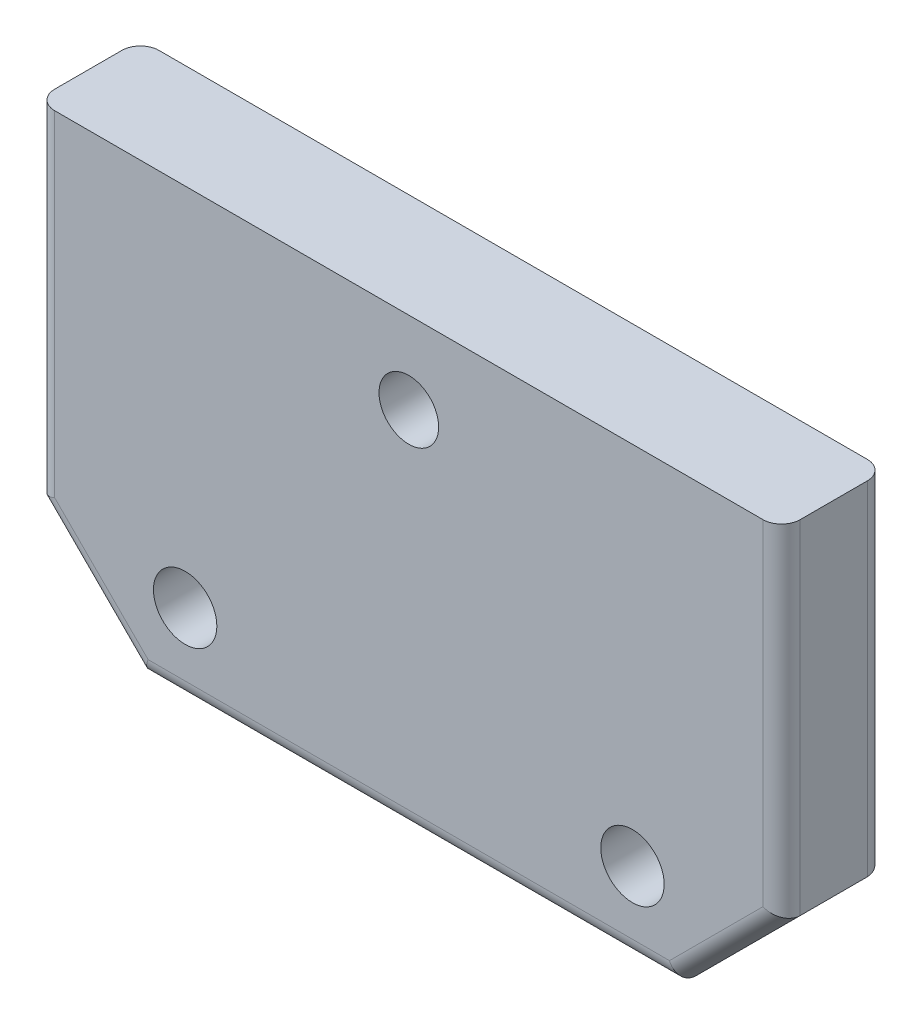
from build123d import *

# Parameters (mm, degrees)
SKETCH1_W           = 100
SKETCH1_H           = 60
SKETCH1_R           = 4.25
SKETCH1_R_2         = 4
BOSS_EXTRUDE1_DEPTH = 7
SKETCH2_R           = 6.457332118
BOSS_EXTRUDE2_DEPTH = 6
CHAMFER1_SIZE       = 14
FILLET2_R           = 2.5
SKETCH3_W           = 30
SKETCH3_H           = 22
CUT_EXTRUDE1_DEPTH  = 6
SKETCH4_R           = 1.25
CUT_EXTRUDE2_DEPTH  = 12


with BuildPart() as part:
    # Sketch1 → Boss-Extrude1 (new body, symmetric)
    with BuildSketch(Plane.XY):
        with Locations((0, 20)):
            Rectangle(SKETCH1_W, SKETCH1_H)
        with Locations((30, 1)):
            Circle(SKETCH1_R, mode=Mode.SUBTRACT)
        with Locations((-30, 1)):
            Circle(SKETCH1_R, mode=Mode.SUBTRACT)
        with Locations((0, 39)):
            Circle(SKETCH1_R_2, mode=Mode.SUBTRACT)
    extrude(amount=BOSS_EXTRUDE1_DEPTH, both=True)

    # Sketch2 → Boss-Extrude2 (add)
    with BuildSketch(Plane(origin=(0, 0, -7), x_dir=(-1, 0, 0), z_dir=(0, 0, -1))):
        with Locations((-30, 1)):
            Circle(SKETCH2_R)
        with Locations((30, 1)):
            Circle(SKETCH2_R)
    extrude(amount=-BOSS_EXTRUDE2_DEPTH)

    # Chamfer1
    chamfer1_edges = [part.edges().sort_by_distance(p)[0] for p in [
        (50, -10, 0),
        (-50, -10, 0),
    ]]
    chamfer(chamfer1_edges, length=CHAMFER1_SIZE)

    # Fillet2
    fillet2_edges = [part.edges().sort_by_distance(p)[0] for p in [
        (0, -10, -7),
        (0, -10, 7),
        (-50, 27, 7),
        (50, 27, -7),
        (43, -3, -7),
        (-43, -3, -7),
        (50, 27, 7),
        (43, -3, 7),
        (-43, -3, 7),
        (-50, 27, -7),
    ]]
    fillet(fillet2_edges, radius=FILLET2_R)

    # Sketch3 → Cut-Extrude1 (cut)
    with BuildSketch(Plane(origin=(0, 0, -7), x_dir=(-1, 0, 0), z_dir=(0, 0, -1))):
        with Locations((0, 16.881077189)):
            Rectangle(SKETCH3_W, SKETCH3_H)
    extrude(amount=-CUT_EXTRUDE1_DEPTH, mode=Mode.SUBTRACT)

    # Sketch4 → Cut-Extrude2 (cut)
    with BuildSketch(Plane.XZ.offset(10)):
        with Locations((30, 1)):
            Circle(SKETCH4_R)
        with Locations((-30, 1)):
            Circle(SKETCH4_R)
    extrude(amount=-CUT_EXTRUDE2_DEPTH, mode=Mode.SUBTRACT)


solid = part.part
